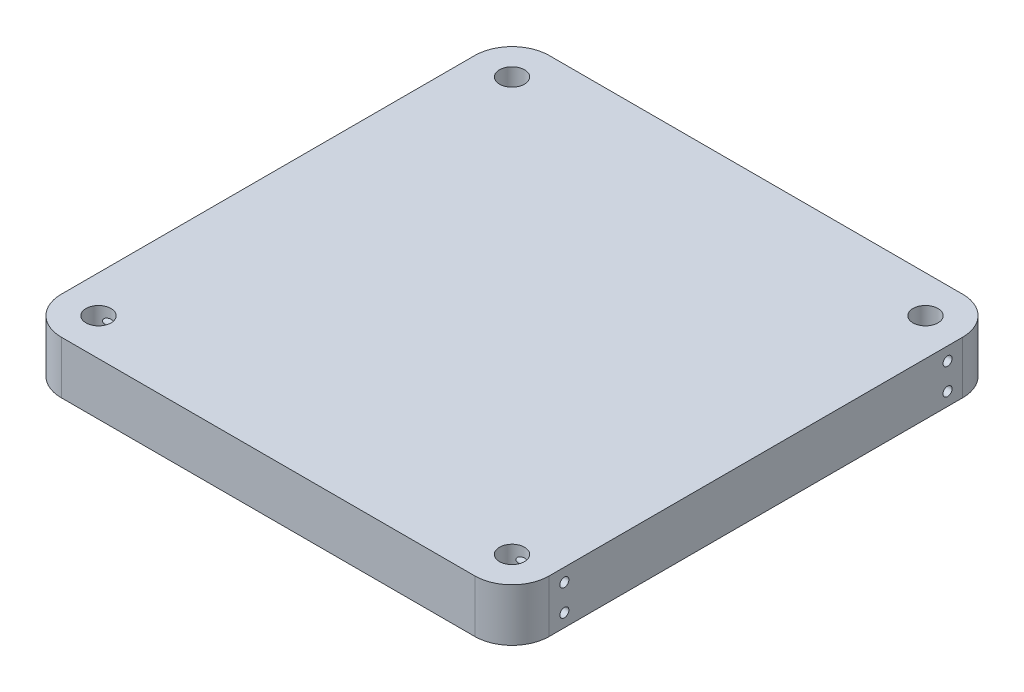
from build123d import *

# Parameters (mm, degrees)
SKETCH1_R           = 3.025
BOSS_EXTRUDE1_DEPTH = 12.7
SKETCH2_R           = 1.095
CUT_EXTRUDE1_DEPTH  = 15


with BuildPart() as part:
    # Sketch1 → Boss-Extrude1 (new body)
    with BuildSketch(Plane(origin=(0, 0, 0), x_dir=(1, 0, 0), z_dir=(0, 1, 0))):
        with BuildLine():
            Line((-50, 59), (50, 59))
            ThreePointArc((50, 59), (56.363961031, 56.363961031), (59, 50))
            Line((59, 50), (59, -50))
            ThreePointArc((59, -50), (56.363961031, -56.363961031), (50, -59))
            Line((50, -59), (-50, -59))
            ThreePointArc((-50, -59), (-56.363961031, -56.363961031), (-59, -50))
            Line((-59, -50), (-59, 50))
            ThreePointArc((-59, 50), (-56.363961031, 56.363961031), (-50, 59))
        make_face()
        with Locations(Location((50, 50, 0), (0, 0, 270))):  # turned: the seam where the file's is
            Circle(SKETCH1_R, mode=Mode.SUBTRACT)
        with Locations(Location((50, -50, 0), (0, 0, 270))):  # turned: the seam where the file's is
            Circle(SKETCH1_R, mode=Mode.SUBTRACT)
        with Locations(Location((-50, 50, 0), (0, 0, 270))):  # turned: the seam where the file's is
            Circle(SKETCH1_R, mode=Mode.SUBTRACT)
        with Locations(Location((-50, -50, 0), (0, 0, 270))):  # turned: the seam where the file's is
            Circle(SKETCH1_R, mode=Mode.SUBTRACT)
    extrude(amount=BOSS_EXTRUDE1_DEPTH)

    # Sketch2 → Cut-Extrude1 (cut)
    with BuildSketch(Plane(origin=(59, 0, 0), x_dir=(0, 0, -1), z_dir=(1, 0, 0))):
        with Locations((-46.34, 9.525)):
            Circle(SKETCH2_R)
        with Locations((-46.34, 3.175)):
            Circle(SKETCH2_R)
        with Locations((46.34, 9.525)):
            Circle(SKETCH2_R)
        with Locations((46.34, 3.175)):
            Circle(SKETCH2_R)
    cut_extrude1 = extrude(amount=-CUT_EXTRUDE1_DEPTH, mode=Mode.SUBTRACT)

    # Mirror1: Cut-Extrude1 across plane
    add(cut_extrude1.mirror(Plane(origin=(0, 0, 0), x_dir=(0, 0, 1), z_dir=(1, 0, 0))), mode=Mode.SUBTRACT)


solid = part.part
